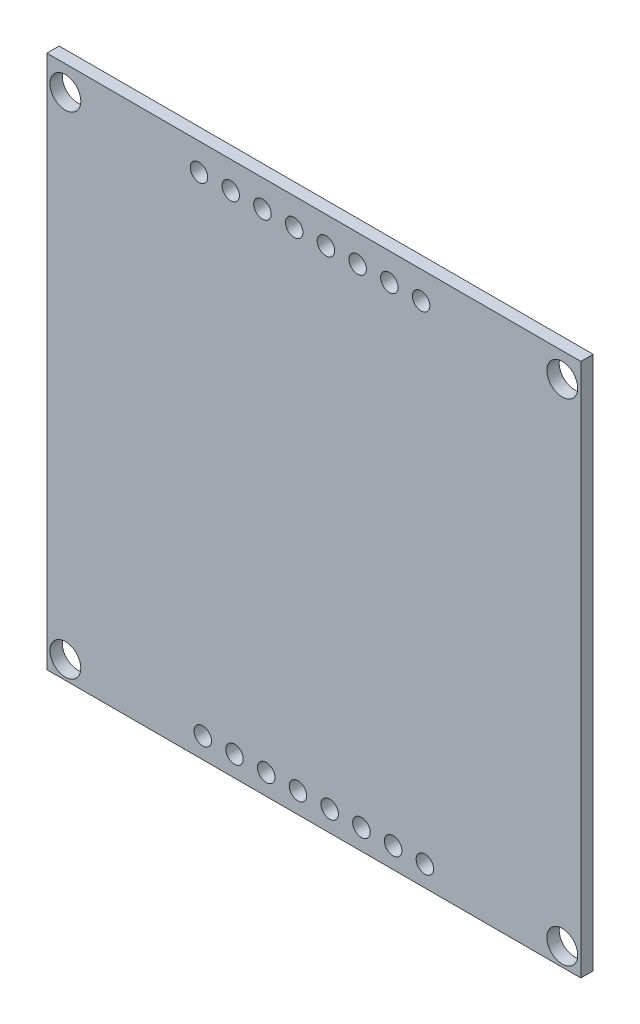
from build123d import *

# Parameters (mm, degrees)
ESBO_O1_W                = 43.25
ESBO_O1_H                = 43.25
ESBO_O1_R                = 1.25
ESBO_O1_R_2              = 0.707384329
RESSALTO_EXTRUS_O2_DEPTH = 1


with BuildPart() as part:
    # Esboço1 → Ressalto-extrusão2 (new body)
    with BuildSketch(Plane.XY):
        with Locations((21.625, 21.625)):
            Rectangle(ESBO_O1_W, ESBO_O1_H)
        with Locations((1.5, 41.25)):
            Circle(ESBO_O1_R, mode=Mode.SUBTRACT)
        with Locations((12.322576567, 41.05)):
            Circle(ESBO_O1_R_2, mode=Mode.SUBTRACT)
        with Locations((41.75, 41.25)):
            Circle(ESBO_O1_R, mode=Mode.SUBTRACT)
        with Locations((14.892575201, 41.047350464)):
            Circle(ESBO_O1_R_2, mode=Mode.SUBTRACT)
        with Locations((17.462573835, 41.044700929)):
            Circle(ESBO_O1_R_2, mode=Mode.SUBTRACT)
        with Locations((20.03257247, 41.042051393)):
            Circle(ESBO_O1_R_2, mode=Mode.SUBTRACT)
        with Locations((22.602571104, 41.039401857)):
            Circle(ESBO_O1_R_2, mode=Mode.SUBTRACT)
        with Locations((25.172569738, 41.036752321)):
            Circle(ESBO_O1_R_2, mode=Mode.SUBTRACT)
        with Locations((27.742568372, 41.034102786)):
            Circle(ESBO_O1_R_2, mode=Mode.SUBTRACT)
        with Locations((30.312567007, 41.03145325)):
            Circle(ESBO_O1_R_2, mode=Mode.SUBTRACT)
        with Locations((30.62, 1.67673648)):
            Circle(ESBO_O1_R_2, mode=Mode.SUBTRACT)
        with Locations((28.05, 1.67673648)):
            Circle(ESBO_O1_R_2, mode=Mode.SUBTRACT)
        with Locations((25.48, 1.67673648)):
            Circle(ESBO_O1_R_2, mode=Mode.SUBTRACT)
        with Locations((22.91, 1.67673648)):
            Circle(ESBO_O1_R_2, mode=Mode.SUBTRACT)
        with Locations((20.34, 1.67673648)):
            Circle(ESBO_O1_R_2, mode=Mode.SUBTRACT)
        with Locations((17.77, 1.67673648)):
            Circle(ESBO_O1_R_2, mode=Mode.SUBTRACT)
        with Locations((15.2, 1.67673648)):
            Circle(ESBO_O1_R_2, mode=Mode.SUBTRACT)
        with Locations((41.75, 1.47673648)):
            Circle(ESBO_O1_R, mode=Mode.SUBTRACT)
        with Locations((12.63, 1.67673648)):
            Circle(ESBO_O1_R_2, mode=Mode.SUBTRACT)
        with Locations((1.5, 1.47673648)):
            Circle(ESBO_O1_R, mode=Mode.SUBTRACT)
    extrude(amount=RESSALTO_EXTRUS_O2_DEPTH)


solid = part.part
